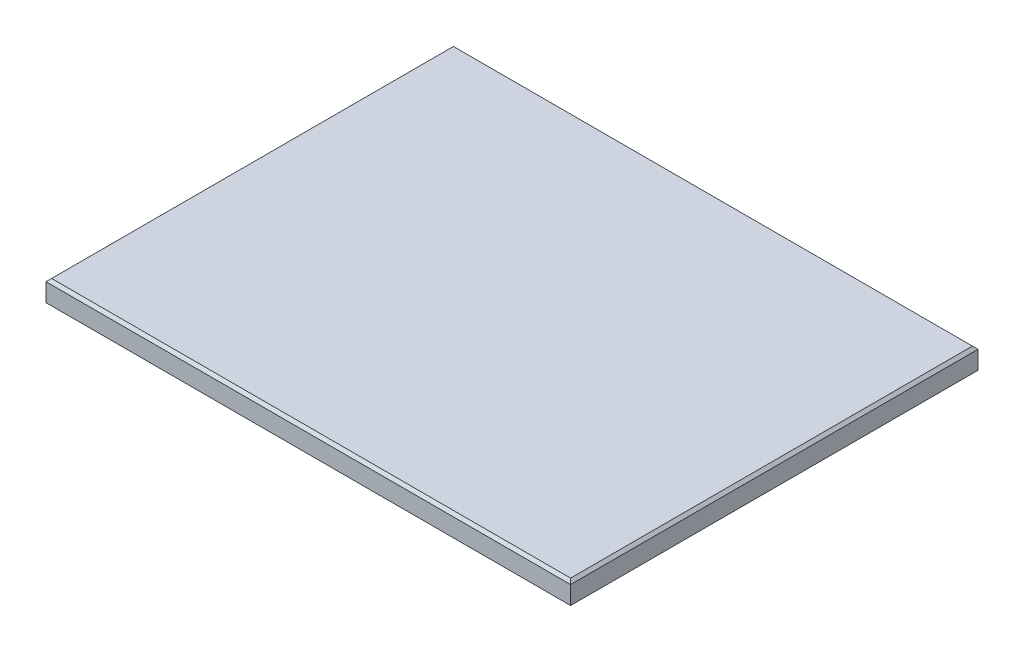
from build123d import *

# Parameters (mm, degrees)
SKETCH1_W           = 476.25
SKETCH1_H           = 369.8875
BOSS_EXTRUDE1_DEPTH = 19.05
CHAMFER1_SIZE       = 2.54


with BuildPart() as part:
    # Sketch1 → Boss-Extrude1 (new body)
    with BuildSketch(Plane(origin=(0, 0, 0), x_dir=(1, 0, 0), z_dir=(0, 1, 0))):
        with Locations((238.125, 184.94375)):
            Rectangle(SKETCH1_W, SKETCH1_H)
    extrude(amount=BOSS_EXTRUDE1_DEPTH)

    # Chamfer1
    chamfer1_edges = [part.edges().sort_by_distance(p)[0] for p in [
        (476.25, 19.05, -184.94375),
        (238.125, 19.05, -369.8875),
        (0, 19.05, -184.94375),
        (238.125, 19.05, 0),
    ]]
    chamfer(chamfer1_edges, length=CHAMFER1_SIZE)


solid = part.part
